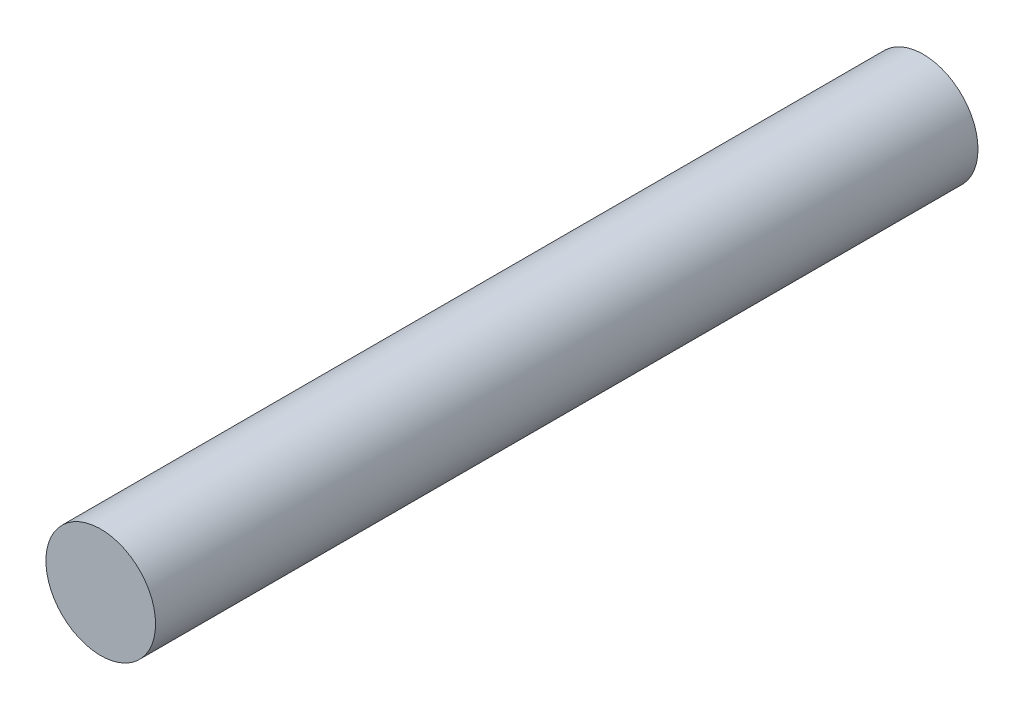
from build123d import *

# Parameters (mm, degrees)
SKETCH1_R           = 1
BOSS_EXTRUDE1_DEPTH = 15


with BuildPart() as part:
    # Sketch1 → Boss-Extrude1 (new body)
    with BuildSketch(Plane.XY):
        Circle(SKETCH1_R)
    extrude(amount=BOSS_EXTRUDE1_DEPTH)


solid = part.part
